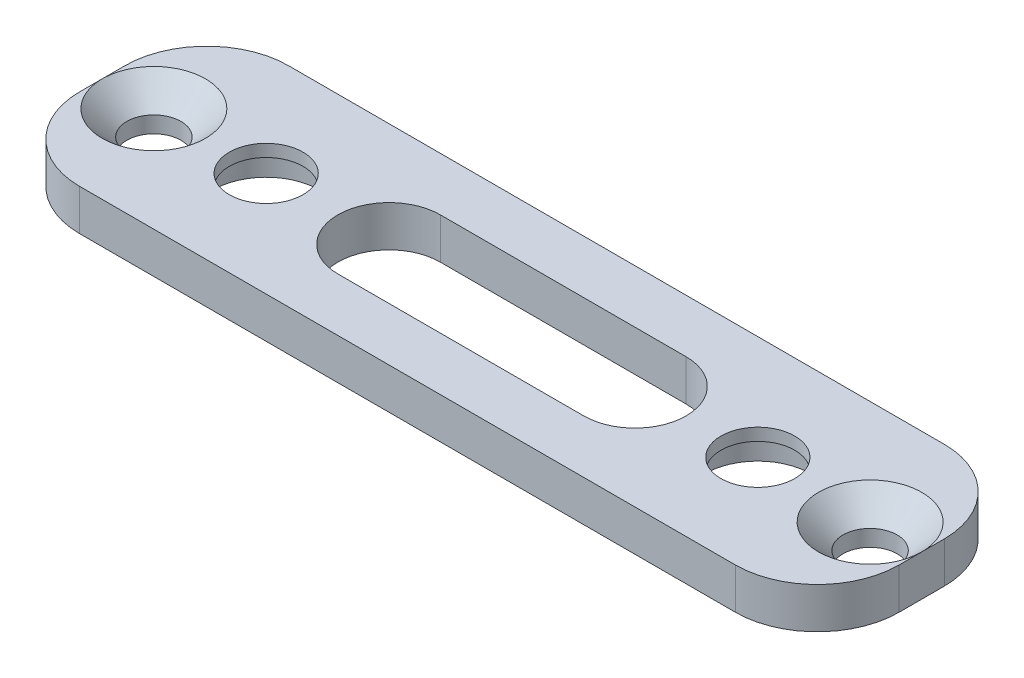
from build123d import *

# Parameters (mm, degrees)
SKETCH1_W                                           = 100
SKETCH1_H                                           = 7
BOSS_EXTRUDE1_DEPTH                                 = 25.5
CSK_FOR_M6_COUNTERSUNK_FLAT_HEAD_SCREW1_D           = 6.6
CSK_FOR_M6_COUNTERSUNK_FLAT_HEAD_SCREW1_CSINK_D     = 12.6
CSK_FOR_M6_COUNTERSUNK_FLAT_HEAD_SCREW1_CSINK_ANGLE = 90
SKETCH2_R                                           = 4.5
CUT_EXTRUDE2_DEPTH                                  = 3
SKETCH2_4_R                                         = 4.5
CUT_EXTRUDE3_DEPTH                                  = 3
SKETCH6_R                                           = 6.5
CUT_EXTRUDE4_DEPTH                                  = 1.5
SKETCH9_R                                           = 6.5
CUT_EXTRUDE5_DEPTH                                  = 104.2775387
SKETCH10_W                                          = 100
SKETCH10_H                                          = 25.5
CUT_EXTRUDE6_DEPTH                                  = 2
CUT_EXTRUDE7_DEPTH                                  = 104.321101427
FILLET4_R                                           = 10


with BuildPart() as part:
    # Sketch1 → Boss-Extrude1 (new body)
    with BuildSketch(Plane.XY):
        with Locations((50, 3.5)):
            Rectangle(SKETCH1_W, SKETCH1_H)
    extrude(amount=BOSS_EXTRUDE1_DEPTH)

    # CSK for M6 Countersunk Flat Head Screw1 (through all)
    with Locations(Plane(origin=(0, 7, 0), x_dir=(1, 0, 0), z_dir=(0, 1, 0))):
        with Locations((93.7, -12.75), (6.298395044, -12.75)):
            CounterSinkHole(CSK_FOR_M6_COUNTERSUNK_FLAT_HEAD_SCREW1_D / 2, CSK_FOR_M6_COUNTERSUNK_FLAT_HEAD_SCREW1_CSINK_D / 2, counter_sink_angle=CSK_FOR_M6_COUNTERSUNK_FLAT_HEAD_SCREW1_CSINK_ANGLE)

    # Sketch2 → Cut-Extrude2 (cut)
    with BuildSketch(Plane(origin=(0, 7, 0), x_dir=(1, 0, 0), z_dir=(0, 1, 0))):
        with Locations((20, -12.75)):
            Circle(SKETCH2_R)
    extrude(amount=-CUT_EXTRUDE2_DEPTH, mode=Mode.SUBTRACT)

    # Sketch2_4 → Cut-Extrude3 (cut)
    with BuildSketch(Plane(origin=(0, 7, 0), x_dir=(1, 0, 0), z_dir=(0, 1, 0))):
        with Locations((80, -12.75)):
            Circle(SKETCH2_4_R)
        with Locations((20, -12.75)):
            Circle(SKETCH2_4_R)
    extrude(amount=-CUT_EXTRUDE3_DEPTH, mode=Mode.SUBTRACT)

    # Sketch6 → Cut-Extrude4 (cut)
    with BuildSketch(Plane(origin=(0, 4, 0), x_dir=(1, 0, 0), z_dir=(0, 1, 0))):
        with Locations((20, -12.75)):
            Circle(SKETCH6_R)
        with Locations((80, -12.75)):
            Circle(SKETCH6_R)
    extrude(amount=CUT_EXTRUDE4_DEPTH, mode=Mode.SUBTRACT)

    # Sketch9 → Cut-Extrude5 (cut, through all)
    with BuildSketch(Plane(origin=(0, 4, 0), x_dir=(1, 0, 0), z_dir=(0, 1, 0))):
        with Locations((20, -12.75)):
            Circle(SKETCH9_R)
        with Locations((80, -12.75)):
            Circle(SKETCH9_R)
    extrude(amount=-CUT_EXTRUDE5_DEPTH, mode=Mode.SUBTRACT)

    # Sketch10 → Cut-Extrude6 (cut)
    with BuildSketch(Plane.XZ):
        with Locations((50, 12.75)):
            Rectangle(SKETCH10_W, SKETCH10_H)
    extrude(amount=-CUT_EXTRUDE6_DEPTH, mode=Mode.SUBTRACT)

    # Sketch11 → Cut-Extrude7 (cut, through all)
    with BuildSketch(Plane(origin=(0, 7, 0), x_dir=(1, 0, 0), z_dir=(0, 1, 0))):
        with BuildLine():
            Line((35, -19), (65, -19))
            ThreePointArc((65, -19), (71.25, -12.75), (65, -6.5))
            Line((65, -6.5), (35, -6.5))
            ThreePointArc((35, -6.5), (28.75, -12.75), (35, -19))
        make_face()
    extrude(amount=-CUT_EXTRUDE7_DEPTH, mode=Mode.SUBTRACT)

    # Fillet4
    fillet4_edges = [part.edges().sort_by_distance(p)[0] for p in [
        (100, 4.5, 25.5),
        (100, 4.5, 0),
        (0, 4.5, 0),
        (0, 4.5, 25.5),
    ]]
    fillet(fillet4_edges, radius=FILLET4_R)


solid = part.part
